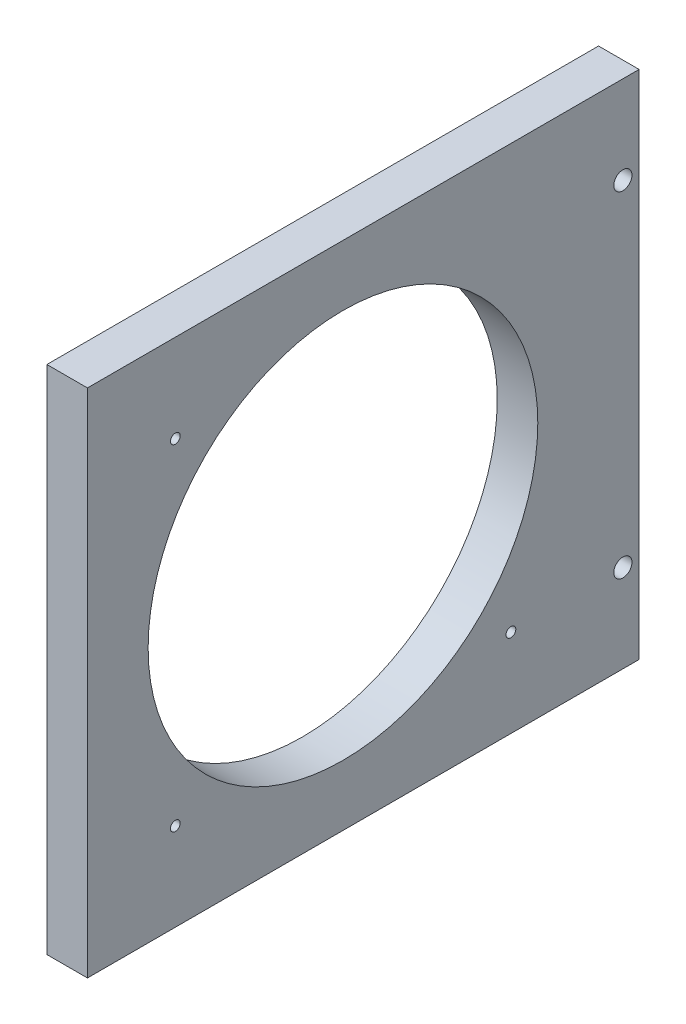
from build123d import *

# Parameters (mm, degrees)
SKETCH1_W           = 86.36
SKETCH1_H           = 80
SKETCH1_R           = 30.5
BOSS_EXTRUDE1_DEPTH = 6.35
SKETCH3_R           = 0.762
SKETCH3_R_2         = 1.4224
CUT_EXTRUDE2_DEPTH  = 6.35


with BuildPart() as part:
    # Sketch1 → Boss-Extrude1 (new body)
    with BuildSketch(Plane(origin=(0, 0, 0), x_dir=(0, 0, -1), z_dir=(1, 0, 0))):
        with Locations((43.18, 40)):
            Rectangle(SKETCH1_W, SKETCH1_H)
        with Locations((40, 40)):
            Circle(SKETCH1_R, mode=Mode.SUBTRACT)
    extrude(amount=BOSS_EXTRUDE1_DEPTH)

    # Sketch3 → Cut-Extrude2 (cut)
    with BuildSketch(Plane.ZY):
        with Locations((-66.292558248, 13.75)):
            Circle(SKETCH3_R)
        with Locations((-13.754723938, 13.75)):
            Circle(SKETCH3_R)
        with Locations((-13.754723938, 66.25)):
            Circle(SKETCH3_R)
        with Locations((-83.82, 13.75)):
            Circle(SKETCH3_R_2)
        with Locations((-83.82, 66.25)):
            Circle(SKETCH3_R_2)
    extrude(amount=-CUT_EXTRUDE2_DEPTH, mode=Mode.SUBTRACT)


solid = part.part
